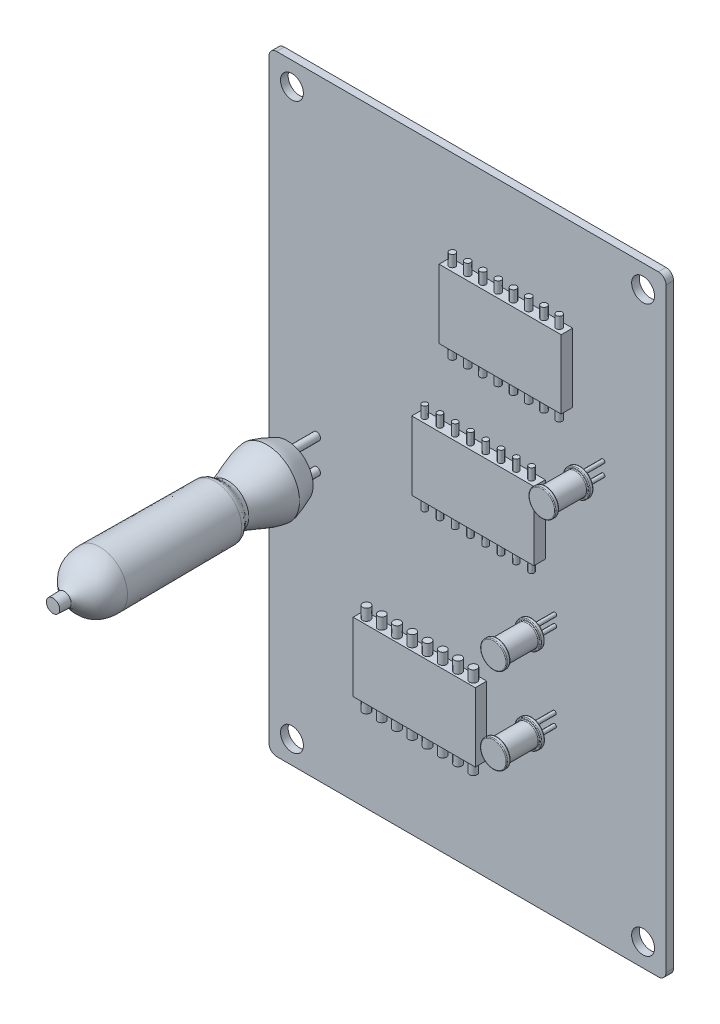
from build123d import *

# Parameters (mm, degrees)
ESQUISSE1_R             = 1.5
BOSS_EXTRU_1_DEPTH      = 1
ESQUISSE3_R             = 0.5
BOSS_EXTRU_2_DEPTH      = 5
ESQUISSE4_W             = 16
ESQUISSE4_H             = 9
ESQUISSE4_H_2           = 9.003329916
BOSS_EXTRU_3_DEPTH      = 1.5
ESQUISSE5_R             = 0.5
BOSS_EXTRU_4_DEPTH      = 1.5
BOSS_EXTRU_4_DEPTH_BACK = 10.5
ESQUISSE6_R             = 0.353814469
BOSS_EXTRU_5_DEPTH      = 1.5
BOSS_EXTRU_5_DEPTH_BACK = 10.5
ESQUISSE7_R             = 0.4
BOSS_EXTRU_6_DEPTH      = 1.5
BOSS_EXTRU_6_DEPTH_BACK = 10.5
BOSS_EXTRU_7_START      = 3
ESQUISSE8_R             = 1.75
BOSS_EXTRU_7_DEPTH      = 0.5
ESQUISSE8_R_2           = 1.725
BOSS_EXTRU_7_2_DEPTH    = 0.5
BOSS_EXTRU_7_3_DEPTH    = 0.5
ESQUISSE9_R             = 1.45
ESQUISSE9_R_2           = 1.425
BOSS_EXTRU_8_DEPTH      = 4
ESQUISSE10_R            = 1.725
ESQUISSE10_R_2          = 1.75
BOSS_EXTRU_9_DEPTH      = 0.5
CONG_1_R                = 0.1
CONG_2_R                = 0.1
CONG_3_R                = 0.1
ESQUISSE11_R            = 0.25
BOSS_EXTRU_10_DEPTH     = 3
CONG_4_R                = 0.1
CONG_5_R                = 0.1
CONG_6_R                = 0.1
BOSS_EXTRU_11_REACH     = 6.151
ESQUISSE12_R            = 0.25
BOSS_EXTRU_12_REACH     = 6.151
ESQUISSE14_R            = 0.25


with BuildPart() as part:
    # Esquisse1 → Boss.-Extru.1 (new body)
    with BuildSketch(Plane.XY):
        with BuildLine():
            Line((-25, 40), (25, 40))
            ThreePointArc((25, 40), (25.707106781, 39.707106781), (26, 39))
            Line((26, 39), (26, -39))
            ThreePointArc((26, -39), (25.707106781, -39.707106781), (25, -40))
            Line((25, -40), (-25, -40))
            ThreePointArc((-25, -40), (-25.707106781, -39.707106781), (-26, -39))
            Line((-26, -39), (-26, 39))
            ThreePointArc((-26, 39), (-25.707106781, 39.707106781), (-25, 40))
        make_face()
        with Locations((-23, 37)):
            Circle(ESQUISSE1_R, mode=Mode.SUBTRACT)
        with Locations((23, 37)):
            Circle(ESQUISSE1_R, mode=Mode.SUBTRACT)
        with Locations((23, -37)):
            Circle(ESQUISSE1_R, mode=Mode.SUBTRACT)
        with Locations((-23, -37)):
            Circle(ESQUISSE1_R, mode=Mode.SUBTRACT)
    extrude(amount=BOSS_EXTRU_1_DEPTH)



with BuildPart() as body_2:
    # Esquisse2 → Révolution1 (revolve)
    with BuildSketch(Plane.ZY.offset(19.761844801)):
        with BuildLine():
            Line((4.8485412, -6.38850987), (4.8485412, -3.005192344))
            Line((4.8485412, -3.005192344), (35.547732455, -3.005192344))
            add(Edge.make_bspline(
                [(35.547732455, -3.005192344), (35.530974347, -3.881155613)],
                knots=[0, 0, 1, 1], degree=1))
            add(Edge.make_bspline(
                [(35.530974347, -3.881155613), (34.903135866, -3.914870791), (34.078007479, -3.931967877)],
                knots=[0, 0, 0, 1, 1, 1], degree=2))
            add(Edge.make_bspline(
                [(34.078007479, -3.931967877), (32.989313164, -4.19714909), (32.748086016, -6.683067274), (29.408481231, -6.629511176)],
                knots=[0, 0, 0, 0, 1, 1, 1, 1], degree=3))
            add(Edge.make_bspline(
                [(29.408481231, -6.629511176), (14.330665921, -6.521677377)],
                knots=[0, 0, 1, 1], degree=1))
            add(Edge.make_bspline(
                [(14.330665921, -6.521677377), (13.437973486, -6.531935835), (13.644094014, -5.817363834), (12.629696846, -5.746178068)],
                knots=[0, 0, 0, 0, 1, 1, 1, 1], degree=3))
            add(Edge.make_bspline(
                [(12.629696846, -5.746178068), (11.668689595, -5.835160221), (9.497172284, -7.055709003), (7.510416443, -7.267473659)],
                knots=[0, 0, 0, 0, 1, 1, 1, 1], degree=3))
            add(Edge.make_bspline(
                [(7.510416443, -7.267473659), (6.889050683, -7.230922732), (5.394562791, -6.585843382), (4.8485412, -6.38850987)],
                knots=[0, 0, 0, 0, 1, 1, 1, 1], degree=3))
        make_face()
    revolve(axis=Axis((-19.761844801, -3.005192344, 35.547732455), (0, 0, -1)))


with BuildPart() as part_1:
    add(part.part)

    add(body_2.part)  # Boss.-Extru.2 merges body 2
    # Esquisse3 → Boss.-Extru.2 (add)
    with BuildSketch(Plane(origin=(0, 0, 4.8485412), x_dir=(-1, 0, 0), z_dir=(0, 0, -1))):
        with Locations((19.761844801, -1.023031737)):
            Circle(ESQUISSE3_R)
        with Locations((19.761844801, -4.987352951)):
            Circle(ESQUISSE3_R)
    extrude(amount=BOSS_EXTRU_2_DEPTH)

    # Esquisse4 → Boss.-Extru.3 (add)
    with BuildSketch(Plane.XY.offset(1)):
        with Locations((5.769798695, 23.499674161)):
            Rectangle(ESQUISSE4_W, ESQUISSE4_H)
        with Locations((2.194947111, 4.5)):
            Rectangle(ESQUISSE4_W, ESQUISSE4_H)
        with Locations((-5.4843637, -22.177320014)):
            Rectangle(ESQUISSE4_W, ESQUISSE4_H_2)
    extrude(amount=BOSS_EXTRU_3_DEPTH)

    # Esquisse5 → Boss.-Extru.4 (add, two sides)
    with BuildSketch(Plane.XZ.offset(26.678984972)) as boss_extru_4_sk:
        with Locations((-4.4843637, 1.75)):
            Circle(ESQUISSE5_R)
        with Locations((-2.4843637, 1.75)):
            Circle(ESQUISSE5_R)
        with Locations((-0.4843637, 1.75)):
            Circle(ESQUISSE5_R)
        with Locations((1.5156363, 1.75)):
            Circle(ESQUISSE5_R)
        with Locations((-12.4843637, 1.75)):
            Circle(ESQUISSE5_R)
        with Locations((-10.4843637, 1.75)):
            Circle(ESQUISSE5_R)
        with Locations((-8.4843637, 1.75)):
            Circle(ESQUISSE5_R)
        with Locations((-6.4843637, 1.75)):
            Circle(ESQUISSE5_R)
    extrude(amount=BOSS_EXTRU_4_DEPTH)
    extrude(boss_extru_4_sk.sketch, amount=-BOSS_EXTRU_4_DEPTH_BACK)

    # Esquisse6 → Boss.-Extru.5 (add, two sides)
    with BuildSketch(Plane.XZ) as boss_extru_5_sk:
        with Locations((3.194947111, 1.804106587)):
            Circle(ESQUISSE6_R)
        with Locations((5.194947111, 1.804106587)):
            Circle(ESQUISSE6_R)
        with Locations((7.194947111, 1.804106587)):
            Circle(ESQUISSE6_R)
        with Locations((9.194947111, 1.804106587)):
            Circle(ESQUISSE6_R)
        with Locations((-4.805052889, 1.804106587)):
            Circle(ESQUISSE6_R)
        with Locations((-2.805052889, 1.804106587)):
            Circle(ESQUISSE6_R)
        with Locations((-0.805052889, 1.804106587)):
            Circle(ESQUISSE6_R)
        with Locations((1.194947111, 1.804106587)):
            Circle(ESQUISSE6_R)
    extrude(amount=BOSS_EXTRU_5_DEPTH)
    extrude(boss_extru_5_sk.sketch, amount=-BOSS_EXTRU_5_DEPTH_BACK)

    # Esquisse7 → Boss.-Extru.6 (add, two sides)
    with BuildSketch(Plane.XZ.offset(-18.999674161)) as boss_extru_6_sk:
        with Locations((6.769798695, 1.75)):
            Circle(ESQUISSE7_R)
        with Locations((8.769798695, 1.75)):
            Circle(ESQUISSE7_R)
        with Locations((10.769798695, 1.75)):
            Circle(ESQUISSE7_R)
        with Locations((12.769798695, 1.75)):
            Circle(ESQUISSE7_R)
        with Locations((-1.230201305, 1.75)):
            Circle(ESQUISSE7_R)
        with Locations((0.769798695, 1.75)):
            Circle(ESQUISSE7_R)
        with Locations((2.769798695, 1.75)):
            Circle(ESQUISSE7_R)
        with Locations((4.769798695, 1.75)):
            Circle(ESQUISSE7_R)
    extrude(amount=BOSS_EXTRU_6_DEPTH)
    extrude(boss_extru_6_sk.sketch, amount=-BOSS_EXTRU_6_DEPTH_BACK)



with BuildPart() as body_2_2:
    # Esquisse8 → Boss.-Extru.7 (new body)
    with BuildSketch(Plane.XY.offset(1).offset(BOSS_EXTRU_7_START)):
        with Locations((11.386564306, -17.543253145)):
            Circle(ESQUISSE8_R)
    extrude(amount=BOSS_EXTRU_7_DEPTH)



with BuildPart() as body_3:
    # Esquisse8 → Boss.-Extru.7 2 (new body)
    with BuildSketch(Plane.XY.offset(1).offset(BOSS_EXTRU_7_START)):
        with Locations((11.386564306, -6.28909075)):
            Circle(ESQUISSE8_R_2)
    extrude(amount=BOSS_EXTRU_7_2_DEPTH)


with BuildPart() as body_4:
    # Esquisse8 → Boss.-Extru.7 3 (new body)
    with BuildSketch(Plane.XY.offset(1).offset(BOSS_EXTRU_7_START)):
        with Locations((17.741856011, 14.100803471)):
            Circle(ESQUISSE8_R)
    extrude(amount=BOSS_EXTRU_7_3_DEPTH)


with BuildPart() as body_2_2_1:
    add(body_2_2.part)

    add(body_3.part)  # Boss.-Extru.8 merges body 3

    add(body_4.part)  # Boss.-Extru.8 merges body 4
    # Esquisse9 → Boss.-Extru.8 (add)
    with BuildSketch(Plane.XY.offset(4.5)):
        with Locations((17.741856011, 14.100803471)):
            Circle(ESQUISSE9_R)
        with Locations((11.386564306, -6.28909075)):
            Circle(ESQUISSE9_R_2)
        with Locations((11.386564306, -17.543253145)):
            Circle(ESQUISSE9_R)
    extrude(amount=BOSS_EXTRU_8_DEPTH)

    # Esquisse10 → Boss.-Extru.9 (add)
    with BuildSketch(Plane.XY.offset(8.5)):
        with Locations((11.386564306, -6.28909075)):
            Circle(ESQUISSE10_R)
        with Locations((11.386564306, -17.543253145)):
            Circle(ESQUISSE10_R_2)
        with Locations((17.741856011, 14.100803471)):
            Circle(ESQUISSE10_R_2)
    extrude(amount=BOSS_EXTRU_9_DEPTH)

    # Congé1
    cong_1_edges = [body_2_2_1.edges().sort_by_distance(p)[0] for p in [
        (15.991856011, 14.100803471, 9),
        (15.991856011, 14.100803471, 4),
        (15.991856011, 14.100803471, 4.5),
        (15.991856011, 14.100803471, 8.5),
    ]]
    fillet(cong_1_edges, radius=CONG_1_R)

    # Congé2
    cong_2_edges = [body_2_2_1.edges().sort_by_distance(p)[0] for p in [
        (9.661564306, -6.28909075, 4),
        (9.661564306, -6.28909075, 4.5),
        (9.661564306, -6.28909075, 8.5),
        (9.661564306, -6.28909075, 9),
    ]]
    fillet(cong_2_edges, radius=CONG_2_R)

    # Congé3
    cong_3_edges = [body_2_2_1.edges().sort_by_distance(p)[0] for p in [
        (9.636564306, -17.543253145, 4),
        (9.636564306, -17.543253145, 4.5),
        (9.636564306, -17.543253145, 8.5),
        (9.636564306, -17.543253145, 9),
    ]]
    fillet(cong_3_edges, radius=CONG_3_R)


with BuildPart() as part_2:
    add(part_1.part)

    add(body_2_2_1.part)  # Boss.-Extru.10 merges body 2 2
    # Esquisse11 → Boss.-Extru.10 (add)
    with BuildSketch(Plane(origin=(0, 0, 4), x_dir=(-1, 0, 0), z_dir=(0, 0, -1))):
        with Locations((-17.741856011, 13.304537928)):
            Circle(ESQUISSE11_R)
        with Locations((-17.741856011, 14.897069015)):
            Circle(ESQUISSE11_R)
    extrude(amount=BOSS_EXTRU_10_DEPTH)

    # Congé4
    cong_4_edges = [part_2.edges().sort_by_distance(p)[0] for p in [
        (16.291856011, 14.100803471, 4.5),
        (16.291856011, 14.100803471, 8.5),
    ]]
    fillet(cong_4_edges, radius=CONG_4_R)

    # Congé5
    cong_5_edges = [part_2.edges().sort_by_distance(p)[0] for p in [
        (9.961564306, -6.28909075, 4.5),
        (9.961564306, -6.28909075, 8.5),
    ]]
    fillet(cong_5_edges, radius=CONG_5_R)

    # Congé6
    cong_6_edges = [part_2.edges().sort_by_distance(p)[0] for p in [
        (9.936564306, -17.543253145, 4.5),
        (9.936564306, -17.543253145, 8.5),
    ]]
    fillet(cong_6_edges, radius=CONG_6_R)

    # Esquisse12 → Boss.-Extru.11 (add, up to next)
    with BuildSketch(Plane(origin=(0, 0, 4), x_dir=(-1, 0, 0), z_dir=(0, 0, -1)), mode=Mode.PRIVATE) as boss_extru_11_sk1:
        with Locations((-11.433492534, -6.939172364)):
            Circle(ESQUISSE12_R)
    boss_extru_11_tool1 = extrude(boss_extru_11_sk1.sketch, amount=BOSS_EXTRU_11_REACH, mode=Mode.PRIVATE) - part_2.part
    add(boss_extru_11_tool1.solids().sort_by_distance((11.433493, -6.939172, 4))[0])
    # Esquisse12 → Boss.-Extru.11 (add, up to next)
    with BuildSketch(Plane(origin=(0, 0, 4), x_dir=(-1, 0, 0), z_dir=(0, 0, -1)), mode=Mode.PRIVATE) as boss_extru_11_sk2:
        with Locations((-11.433492534, -5.639009136)):
            Circle(ESQUISSE12_R)
    boss_extru_11_tool2 = extrude(boss_extru_11_sk2.sketch, amount=BOSS_EXTRU_11_REACH, mode=Mode.PRIVATE) - part_2.part
    add(boss_extru_11_tool2.solids().sort_by_distance((11.433493, -5.639009, 4))[0])

    # Esquisse14 → Boss.-Extru.12 (add, up to next)
    with BuildSketch(Plane(origin=(0, 0, 4), x_dir=(-1, 0, 0), z_dir=(0, 0, -1)), mode=Mode.PRIVATE) as boss_extru_12_sk1:
        with Locations((-11.386564306, -18.304414783)):
            Circle(ESQUISSE14_R)
    boss_extru_12_tool1 = extrude(boss_extru_12_sk1.sketch, amount=BOSS_EXTRU_12_REACH, mode=Mode.PRIVATE) - part_2.part
    add(boss_extru_12_tool1.solids().sort_by_distance((11.386564, -18.304415, 4))[0])
    # Esquisse14 → Boss.-Extru.12 (add, up to next)
    with BuildSketch(Plane(origin=(0, 0, 4), x_dir=(-1, 0, 0), z_dir=(0, 0, -1)), mode=Mode.PRIVATE) as boss_extru_12_sk2:
        with Locations((-11.372380587, -16.813623382)):
            Circle(ESQUISSE14_R)
    boss_extru_12_tool2 = extrude(boss_extru_12_sk2.sketch, amount=BOSS_EXTRU_12_REACH, mode=Mode.PRIVATE) - part_2.part
    add(boss_extru_12_tool2.solids().sort_by_distance((11.372381, -16.813623, 4))[0])


solid = part_2.part
